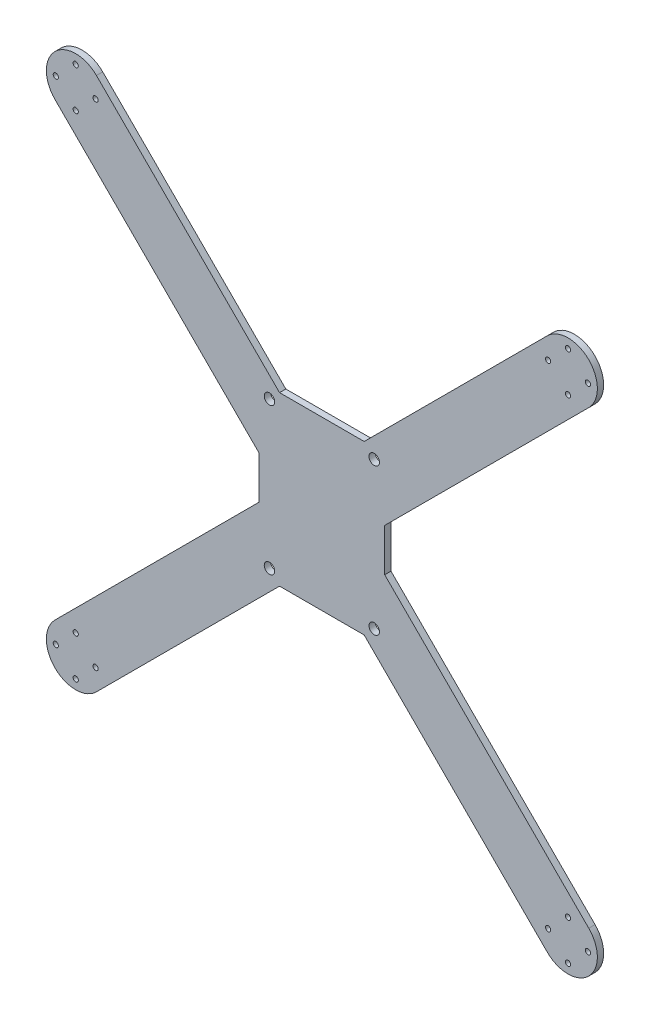
from build123d import *

# Parameters (mm, degrees)
BOSS_EXTRUDE1_DEPTH = 3
SKETCH4_R           = 1.25
SKETCH4_R_2         = 2.5
CUT_EXTRUDE1_DEPTH  = 3


with BuildPart() as part:
    # Sketch1 → Boss-Extrude1 (new body)
    with BuildSketch(Plane.XY):
        with BuildLine():
            Line((20.201010127, 40), (-20.201010127, 40))
            Line((-20.201010127, 40), (-107.600505063, 127.399494937))
            ThreePointArc((-107.600505063, 127.399494937), (-127.399494937, 127.399494937), (-127.399494937, 107.600505063))
            Line((-127.399494937, 107.600505063), (-30, 10.201010127))
            Line((-30, 10.201010127), (-30, -10.201010127))
            Line((-30, -10.201010127), (-127.399494937, -107.600505063))
            ThreePointArc((-127.399494937, -107.600505063), (-127.399494937, -127.399494937), (-107.600505063, -127.399494937))
            Line((-107.600505063, -127.399494937), (-20.201010127, -40))
            Line((-20.201010127, -40), (20.201010127, -40))
            Line((20.201010127, -40), (107.600505063, -127.399494937))
            ThreePointArc((107.600505063, -127.399494937), (127.399494937, -127.399494937), (127.399494937, -107.600505063))
            Line((127.399494937, -107.600505063), (30, -10.201010127))
            Line((30, -10.201010127), (30, 10.201010127))
            Line((30, 10.201010127), (127.399494937, 107.600505063))
            ThreePointArc((127.399494937, 107.600505063), (127.399494937, 127.399494937), (107.600505063, 127.399494937))
            Line((107.600505063, 127.399494937), (20.201010127, 40))
        make_face()
    extrude(amount=-BOSS_EXTRUDE1_DEPTH)

    # Sketch4 → Cut-Extrude1 (cut)
    with BuildSketch(Plane.XY):
        with Locations((-108, 117.5)):
            Circle(SKETCH4_R)
        with Locations((-117.5, 108)):
            Circle(SKETCH4_R)
        with Locations((-127, 117.5)):
            Circle(SKETCH4_R)
        with Locations((-117.5, 127)):
            Circle(SKETCH4_R)
        with Locations((-25, 35)):
            Circle(SKETCH4_R_2)
        with Locations((-117.5, -108)):
            Circle(SKETCH4_R)
        with Locations((-127, -117.5)):
            Circle(SKETCH4_R)
        with Locations((-117.5, -127)):
            Circle(SKETCH4_R)
        with Locations((-108, -117.5)):
            Circle(SKETCH4_R)
        with Locations((-25, -35)):
            Circle(SKETCH4_R_2)
        with Locations((108, -117.5)):
            Circle(SKETCH4_R)
        with Locations((117.5, -127)):
            Circle(SKETCH4_R)
        with Locations((127, -117.5)):
            Circle(SKETCH4_R)
        with Locations((117.5, -108)):
            Circle(SKETCH4_R)
        with Locations((117.5, 108)):
            Circle(SKETCH4_R)
        with Locations((127, 117.5)):
            Circle(SKETCH4_R)
        with Locations((117.5, 127)):
            Circle(SKETCH4_R)
        with Locations((108, 117.5)):
            Circle(SKETCH4_R)
        with Locations((25, -35)):
            Circle(SKETCH4_R_2)
        with Locations((25, 35)):
            Circle(SKETCH4_R_2)
    extrude(amount=-CUT_EXTRUDE1_DEPTH, mode=Mode.SUBTRACT)


solid = part.part
